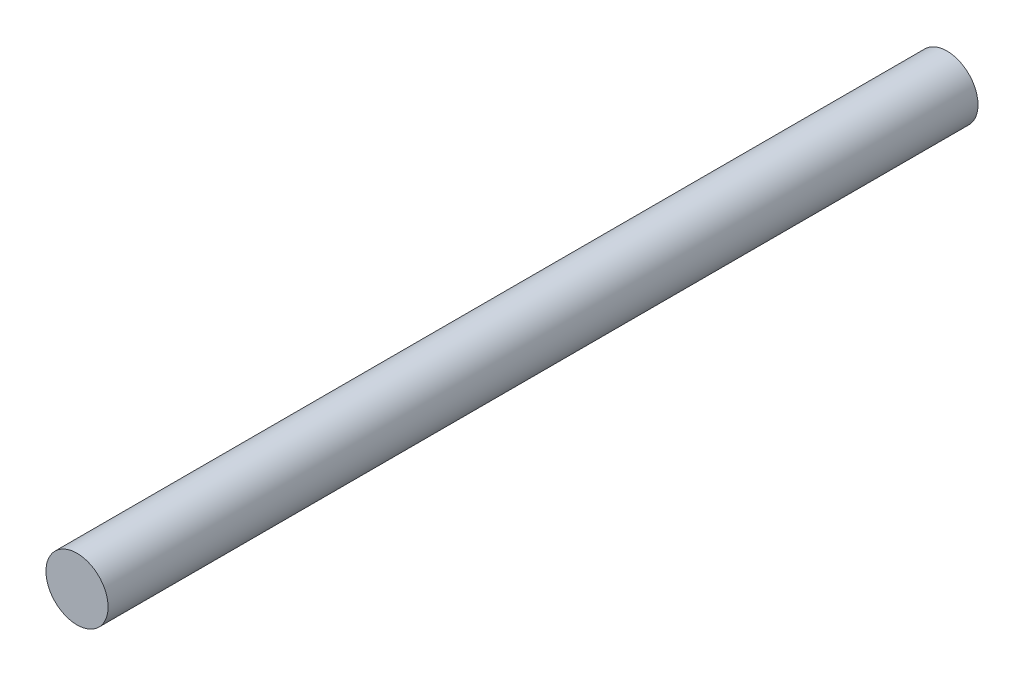
from build123d import *

# Parameters (mm, degrees)
SKETCH1_R           = 2.5
BOSS_EXTRUDE1_DEPTH = 70


with BuildPart() as part:
    # Sketch1 → Boss-Extrude1 (new body)
    with BuildSketch(Plane.XY):
        Circle(SKETCH1_R)
    extrude(amount=BOSS_EXTRUDE1_DEPTH)


solid = part.part
